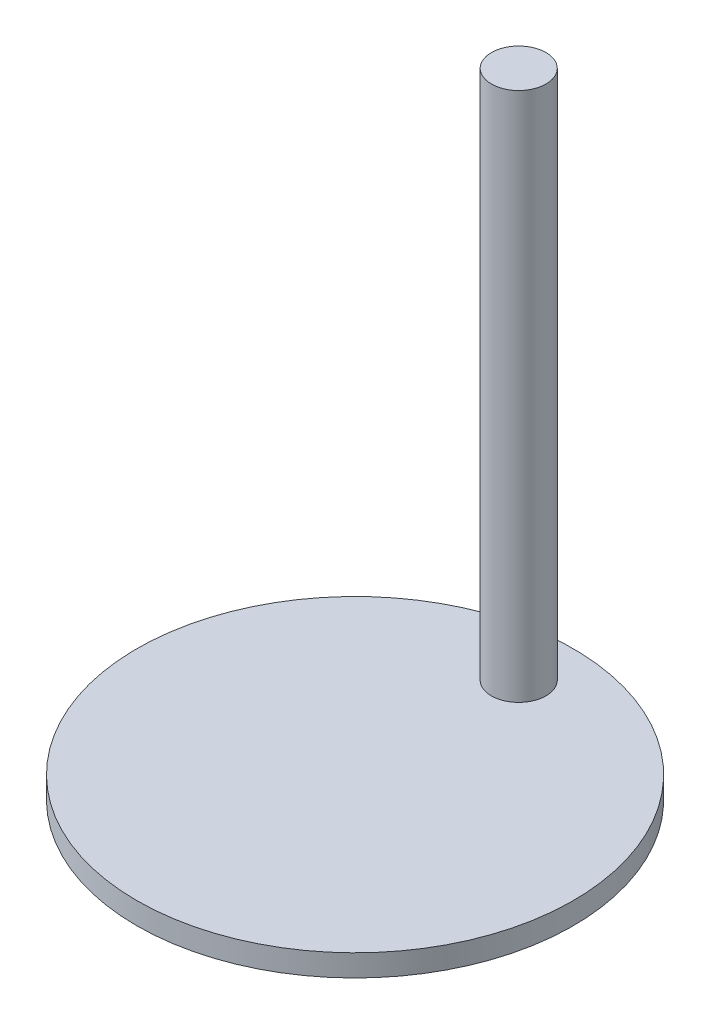
from build123d import *

# Parameters (mm, degrees)
SKETCH1_R           = 5.08
SKETCH1_R_2         = 0.635
BOSS_EXTRUDE1_DEPTH = 0.508
SKETCH2_R           = 0.635
BOSS_EXTRUDE2_DEPTH = 12.844507618


with BuildPart() as part:
    # Sketch1 → Boss-Extrude1 (new body)
    with BuildSketch(Plane(origin=(0, 0, 0), x_dir=(1, 0, 0), z_dir=(0, 1, 0))):
        Circle(SKETCH1_R)
        with Locations((0, 3.81)):
            Circle(SKETCH1_R_2, mode=Mode.SUBTRACT)
    extrude(amount=BOSS_EXTRUDE1_DEPTH)

    # Sketch2 → Boss-Extrude2 (add)
    with BuildSketch(Plane(origin=(0, 0, 0), x_dir=(1, 0, 0), z_dir=(0, 1, 0))):
        with Locations((0, 3.81)):
            Circle(SKETCH2_R)
    extrude(amount=BOSS_EXTRUDE2_DEPTH)


solid = part.part
